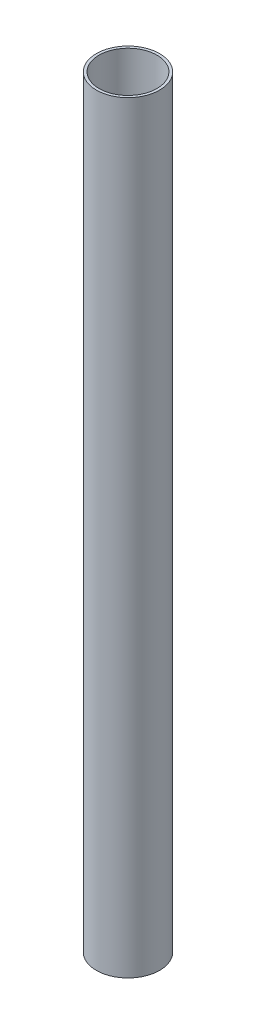
from build123d import *

# Parameters (mm, degrees)
SKETCH1_R           = 41.5
SKETCH1_R_2         = 38
BOSS_EXTRUDE1_DEPTH = 1000


with BuildPart() as part:
    # Sketch1 → Boss-Extrude1 (new body)
    with BuildSketch(Plane(origin=(0, 0, 0), x_dir=(1, 0, 0), z_dir=(0, 1, 0))):
        Circle(SKETCH1_R)
        Circle(SKETCH1_R_2, mode=Mode.SUBTRACT)
    extrude(amount=BOSS_EXTRUDE1_DEPTH)


solid = part.part
